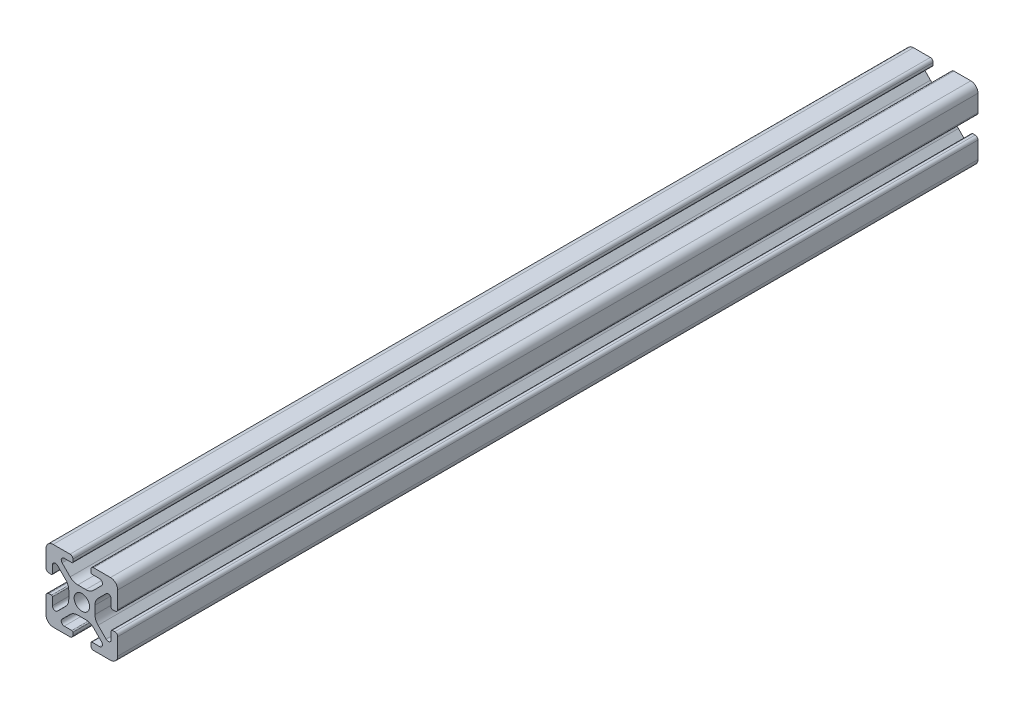
from build123d import *

# Parameters (mm, degrees)
SKETCH1_R           = 2.15
BOSS_EXTRUDE1_DEPTH = 240


with BuildPart() as part:
    # Sketch1 → Boss-Extrude1 (new body)
    with BuildSketch(Plane(origin=(0, 0, 0), x_dir=(-1, 0, 0), z_dir=(0, 0, -1))):
        with BuildLine():
            Line((-12.499999997, 0.800000003), (-12.499999998, 1.500000003))
            ThreePointArc((-12.499999998, 1.500000003), (-12.587867964, 1.712132039), (-12.8, 1.800000005))
            Line((-12.8, 1.800000005), (-14.9175884, 1.800000005))
            ThreePointArc((-14.9175884, 1.800000005), (-15.686636445, 2.313861481), (-15.506192291, 3.221015502))
            Line((-15.506192291, 3.221015502), (-13.255887451, 5.471320342))
            ThreePointArc((-13.255887451, 5.471320342), (-12.282617405, 6.121638595), (-11.134567109, 6.349999998))
            Line((-11.134567109, 6.349999998), (-8.865432906, 6.349999998))
            ThreePointArc((-8.865432906, 6.349999998), (-7.717382611, 6.121638596), (-6.744112565, 5.471320342))
            Line((-6.744112565, 5.471320342), (-4.493807727, 3.221015504))
            ThreePointArc((-4.493807727, 3.221015504), (-4.313363573, 2.313861481), (-5.082411619, 1.800000005))
            Line((-5.082411619, 1.800000005), (-7.20000001, 1.800000005))
            ThreePointArc((-7.20000001, 1.800000005), (-7.412132045, 1.71213204), (-7.50000001, 1.500000005))
            Line((-7.50000001, 1.500000005), (-7.50000001, 0.8))
            ThreePointArc((-7.50000001, 0.8), (-7.265685435, 0.234314575), (-6.70000001, 0))
            Line((-6.70000001, 0), (-2, 0))
            ThreePointArc((-2, 0), (-0.585786438, 0.585786438), (0, 2))
            Line((0, 2), (0, 6.699999998))
            ThreePointArc((0, 6.699999998), (-0.234314576, 7.265685424), (-0.800000003, 7.5))
            Line((-0.800000003, 7.5), (-1.500000007, 7.5))
            ThreePointArc((-1.500000007, 7.5), (-1.712132044, 7.412132033), (-1.80000001, 7.199999997))
            Line((-1.80000001, 7.199999997), (-1.80000001, 5.082411604))
            ThreePointArc((-1.80000001, 5.082411604), (-2.313861485, 4.313363559), (-3.221015507, 4.493807713))
            Line((-3.221015507, 4.493807713), (-5.471320347, 6.744112553))
            ThreePointArc((-5.471320347, 6.744112553), (-6.1216386, 7.717382599), (-6.350000003, 8.865432896))
            Line((-6.350000003, 8.865432896), (-6.350000003, 11.134567105))
            ThreePointArc((-6.350000003, 11.134567105), (-6.121638601, 12.2826174), (-5.471320347, 13.255887446))
            Line((-5.471320347, 13.255887446), (-3.221015511, 15.506192282))
            ThreePointArc((-3.221015511, 15.506192282), (-2.313861487, 15.686636436), (-1.80000001, 14.917588389))
            Line((-1.80000001, 14.917588389), (-1.80000001, 12.799999998))
            ThreePointArc((-1.80000001, 12.799999998), (-1.712132045, 12.587867963), (-1.50000001, 12.499999997))
            Line((-1.50000001, 12.499999997), (-0.8, 12.499999997))
            ThreePointArc((-0.8, 12.499999997), (-0.234314575, 12.734314573), (0, 13.299999998))
            Line((0, 13.299999998), (0, 18))
            ThreePointArc((0, 18), (-0.585786438, 19.414213562), (-2, 20))
            Line((-2, 20), (-6.700000008, 20))
            ThreePointArc((-6.700000008, 20), (-7.265685435, 19.765685424), (-7.50000001, 19.199999998))
            Line((-7.50000001, 19.199999998), (-7.50000001, 18.500000005))
            ThreePointArc((-7.50000001, 18.500000005), (-7.412132044, 18.287867969), (-7.200000008, 18.200000003))
            Line((-7.200000008, 18.200000003), (-5.082411595, 18.200000003))
            ThreePointArc((-5.082411595, 18.200000003), (-4.313363547, 17.686138525), (-4.493807702, 16.7789845))
            Line((-4.493807702, 16.7789845), (-6.744112543, 14.528679659))
            ThreePointArc((-6.744112543, 14.528679659), (-7.717382589, 13.878361405), (-8.865432885, 13.650000003))
            Line((-8.865432885, 13.650000003), (-11.134567111, 13.650000003))
            ThreePointArc((-11.134567111, 13.650000003), (-12.282617406, 13.878361405), (-13.255887452, 14.528679658))
            Line((-13.255887452, 14.528679658), (-15.506192292, 16.778984498))
            ThreePointArc((-15.506192292, 16.778984498), (-15.686636447, 17.686138525), (-14.917588397, 18.200000002))
            Line((-14.917588397, 18.200000002), (-12.799999998, 18.200000003))
            ThreePointArc((-12.799999998, 18.200000003), (-12.587867963, 18.287867968), (-12.499999997, 18.500000002))
            Line((-12.499999997, 18.500000002), (-12.499999997, 19.2))
            ThreePointArc((-12.499999997, 19.2), (-12.734314573, 19.765685425), (-13.299999998, 20))
            Line((-13.299999998, 20), (-18, 20))
            ThreePointArc((-18, 20), (-19.414213562, 19.414213562), (-20, 18))
            Line((-20, 18), (-20, 13.3))
            ThreePointArc((-20, 13.3), (-19.765685424, 12.734314573), (-19.199999998, 12.499999997))
            Line((-19.199999998, 12.499999997), (-18.500000003, 12.499999997))
            ThreePointArc((-18.500000003, 12.499999997), (-18.287867967, 12.587867964), (-18.2, 12.8))
            Line((-18.2, 12.8), (-18.2, 14.91758839))
            ThreePointArc((-18.2, 14.91758839), (-17.686138525, 15.686636435), (-16.778984504, 15.506192281))
            Line((-16.778984504, 15.506192281), (-14.528679657, 13.255887434))
            ThreePointArc((-14.528679657, 13.255887434), (-13.878361403, 12.282617388), (-13.65, 11.134567091))
            Line((-13.65, 11.134567091), (-13.65, 8.865432887))
            ThreePointArc((-13.65, 8.865432887), (-13.878361403, 7.717382591), (-14.528679656, 6.744112546))
            Line((-14.528679656, 6.744112546), (-16.778984496, 4.493807706))
            ThreePointArc((-16.778984496, 4.493807706), (-17.686138522, 4.313363551), (-18.2, 5.0824116))
            Line((-18.2, 5.0824116), (-18.2, 7.2))
            ThreePointArc((-18.2, 7.2), (-18.287867966, 7.412132034), (-18.5, 7.5))
            Line((-18.5, 7.5), (-19.2, 7.5))
            ThreePointArc((-19.2, 7.5), (-19.765685425, 7.265685425), (-20, 6.7))
            Line((-20, 6.7), (-20, 2))
            ThreePointArc((-20, 2), (-19.414213562, 0.585786438), (-18, 0))
            Line((-18, 0), (-13.3, 0))
            ThreePointArc((-13.3, 0), (-12.734314573, 0.234314576), (-12.499999997, 0.800000003))
        make_face()
        with Locations((-10, 10)):
            Circle(SKETCH1_R, mode=Mode.SUBTRACT)
    extrude(amount=-BOSS_EXTRUDE1_DEPTH)


solid = part.part
